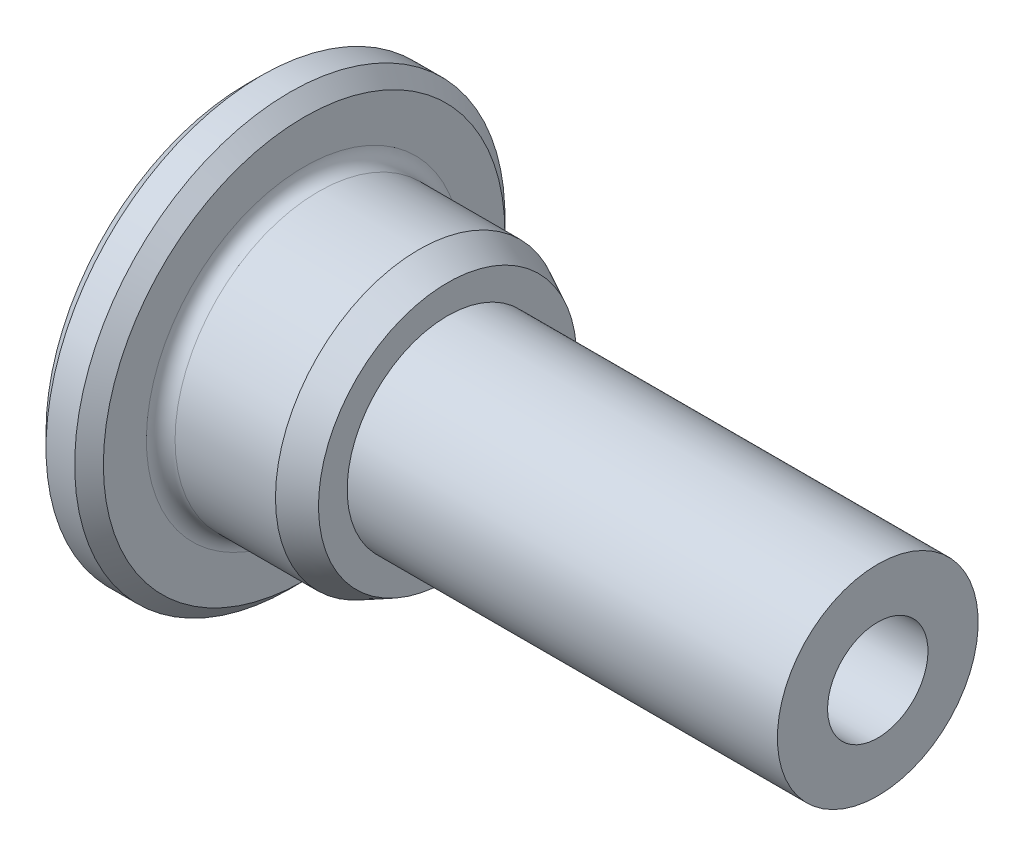
from build123d import *

# Parameters (mm, degrees)
FILLET1_R          = 0.5
CHAMFER1_SIZE      = 0.5
SKETCH2_R          = 1.75
CUT_EXTRUDE1_DEPTH = 23
CHAMFER2_SIZE      = 1


with BuildPart() as part:
    # Sketch1 → Revolve1 (revolve)
    with BuildSketch(Plane.XY):
        Polygon((0, 0), (0, 7.5), (2, 7.5), (2, 5), (6, 5), (7, 4.5), (7, 3.5), (22, 3.5), (22, 0), align=None)
    revolve(axis=Axis((0, 0, 0), (1, 0, 0)))

    # Fillet1
    fillet1_edges = [part.edges().sort_by_distance(p)[0] for p in [
        (2, -5, 0),
    ]]
    fillet(fillet1_edges, radius=FILLET1_R)

    # Chamfer1
    chamfer1_edges = [part.edges().sort_by_distance(p)[0] for p in [
        (2, -7.5, 0),
        (0, -7.5, 0),
    ]]
    chamfer(chamfer1_edges, length=CHAMFER1_SIZE)

    # Sketch2 → Cut-Extrude1 (cut, through all)
    with BuildSketch(Plane(origin=(22, 0, 0), x_dir=(0, 0, -1), z_dir=(1, 0, 0))):
        Circle(SKETCH2_R)
    extrude(amount=-CUT_EXTRUDE1_DEPTH, mode=Mode.SUBTRACT)

    # Chamfer2
    chamfer2_edges = [part.edges().sort_by_distance(p)[0] for p in [
        (0, 0, 1.75),
    ]]
    chamfer(chamfer2_edges, length=CHAMFER2_SIZE)


solid = part.part
